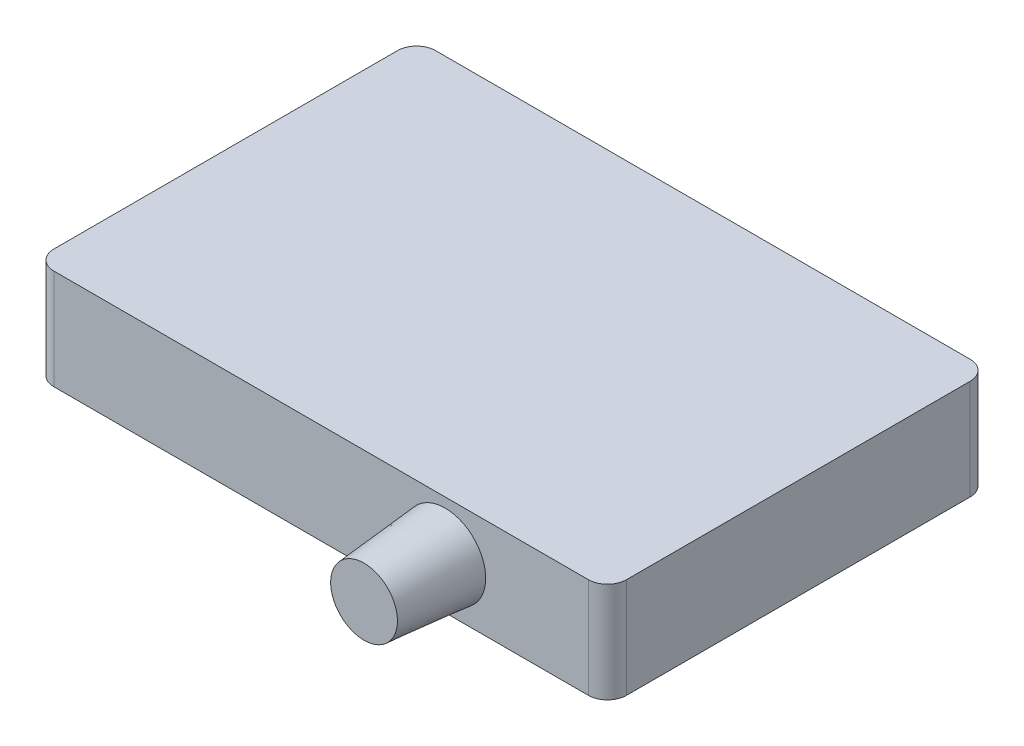
from build123d import *

# Parameters (mm, degrees)
EXTRUDE_1_DEPTH     = 10.5
SKETCH_2_R          = 2.25
CUT_EXTRUDE_1_DEPTH = 4
SKETCH_3_R          = 2.75
SKETCH_3_R_2        = 2.25
EXTRUDE_2_DEPTH     = 0.5
CHAMFER_1_SIZE      = 0.25
SKETCH_4_R          = 3.5
EXTRUDE_3_DEPTH     = 8.5
DRAFT_1_ANGLE       = 5


with BuildPart() as part:
    # 草图1 → 凸台-拉伸1 (new body)
    with BuildSketch(Plane(origin=(0, 0, 0), x_dir=(1, 0, 0), z_dir=(0, 1, 0))):
        with BuildLine():
            Line((-28, 20), (28, 20))
            ThreePointArc((28, 20), (29.414213562, 19.414213562), (30, 18))
            Line((30, 18), (30, -18))
            ThreePointArc((30, -18), (29.414213562, -19.414213562), (28, -20))
            Line((28, -20), (-28, -20))
            ThreePointArc((-28, -20), (-29.414213562, -19.414213562), (-30, -18))
            Line((-30, -18), (-30, 18))
            ThreePointArc((-30, 18), (-29.414213562, 19.414213562), (-28, 20))
        make_face()
    extrude(amount=EXTRUDE_1_DEPTH)

    # 草图2 → 切除-拉伸1 (cut)
    with BuildSketch(Plane(origin=(0, 0, -20), x_dir=(-1, 0, 0), z_dir=(0, 0, -1))):
        with Locations((-18, 4)):
            Circle(SKETCH_2_R)
        with Locations((-12, 4)):
            Circle(SKETCH_2_R)
        with Locations((-6, 4)):
            Circle(SKETCH_2_R)
    extrude(amount=-CUT_EXTRUDE_1_DEPTH, mode=Mode.SUBTRACT)

    # 草图3 → 凸台-拉伸2 (add)
    with BuildSketch(Plane(origin=(0, 0, -20), x_dir=(-1, 0, 0), z_dir=(0, 0, -1))):
        with Locations((-18, 4)):
            Circle(SKETCH_3_R)
        with Locations((-18, 4)):
            Circle(SKETCH_3_R_2, mode=Mode.SUBTRACT)
        with Locations((-12, 4)):
            Circle(SKETCH_3_R)
        with Locations((-12, 4)):
            Circle(SKETCH_3_R_2, mode=Mode.SUBTRACT)
        with Locations((-6, 4)):
            Circle(SKETCH_3_R)
        with Locations((-6, 4)):
            Circle(SKETCH_3_R_2, mode=Mode.SUBTRACT)
    extrude(amount=EXTRUDE_2_DEPTH)

    # 倒角1
    chamfer_1_edges = [part.edges().sort_by_distance(p)[0] for p in [
        (20.75, 4, -20.5),
        (14.75, 4, -20.5),
        (8.75, 4, -20.5),
    ]]
    chamfer(chamfer_1_edges, length=CHAMFER_1_SIZE)

    # 草图4 → 凸台-拉伸3 (add)
    with BuildSketch(Plane.XY.offset(20)):
        with Locations((13, 5.25)):
            Circle(SKETCH_4_R)
    extrude(amount=EXTRUDE_3_DEPTH)

    # 拔模1
    draft_1_faces = [part.faces().sort_by_distance(p)[0] for p in [
        (9.5, 5.25, 24.25),
    ]]
    draft(draft_1_faces, Plane(origin=(13, 5.25, 28.5), x_dir=(1, 0, 0), z_dir=(0, 0, 1)), DRAFT_1_ANGLE)


solid = part.part
